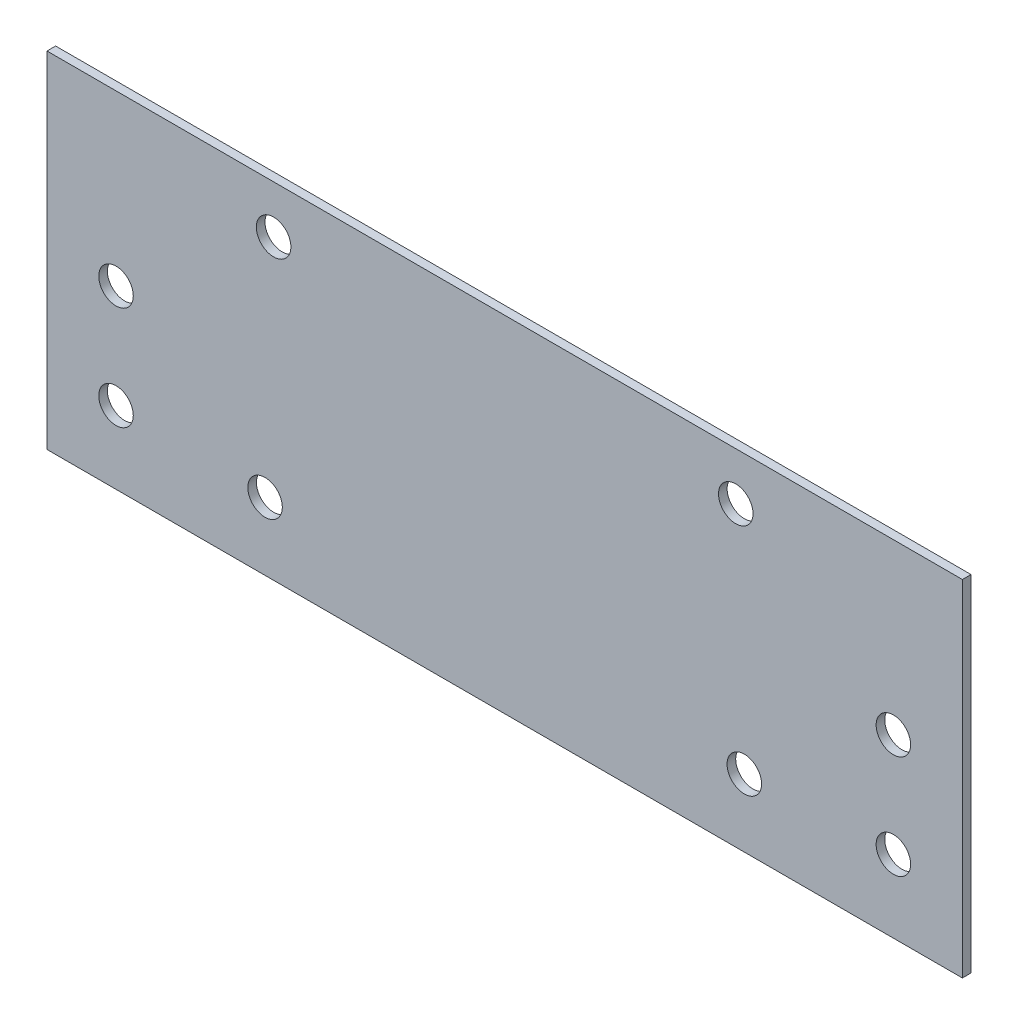
from build123d import *

# Parameters (mm, degrees)
SKETCH1_W           = 168.425
SKETCH1_H           = 63.5
BOSS_EXTRUDE1_DEPTH = 1.5875
SKETCH2_R           = 3.175
CUT_EXTRUDE1_DEPTH  = 2.5875


with BuildPart() as part:
    # Sketch1 → Boss-Extrude1 (new body)
    with BuildSketch(Plane.XY):
        Rectangle(SKETCH1_W, SKETCH1_H)
    extrude(amount=BOSS_EXTRUDE1_DEPTH)

    # Sketch2 → Cut-Extrude1 (cut, through all)
    with BuildSketch(Plane.XY.offset(1.5875)):
        with Locations((-42.515952276, 22.960318249)):
            Circle(SKETCH2_R)
        with Locations((-44.090761728, -19.314587136)):
            Circle(SKETCH2_R)
        with Locations((-71.5125, 0.65024)):
            Circle(SKETCH2_R)
        with Locations((-71.5125, -18.39976)):
            Circle(SKETCH2_R)
        with Locations((71.5149, 0.65024)):
            Circle(SKETCH2_R)
        with Locations((71.5149, -18.39976)):
            Circle(SKETCH2_R)
        with Locations((44.090761728, -19.314587136)):
            Circle(SKETCH2_R)
        with Locations((42.515952276, 22.960318249)):
            Circle(SKETCH2_R)
    extrude(amount=-CUT_EXTRUDE1_DEPTH, mode=Mode.SUBTRACT)


solid = part.part
